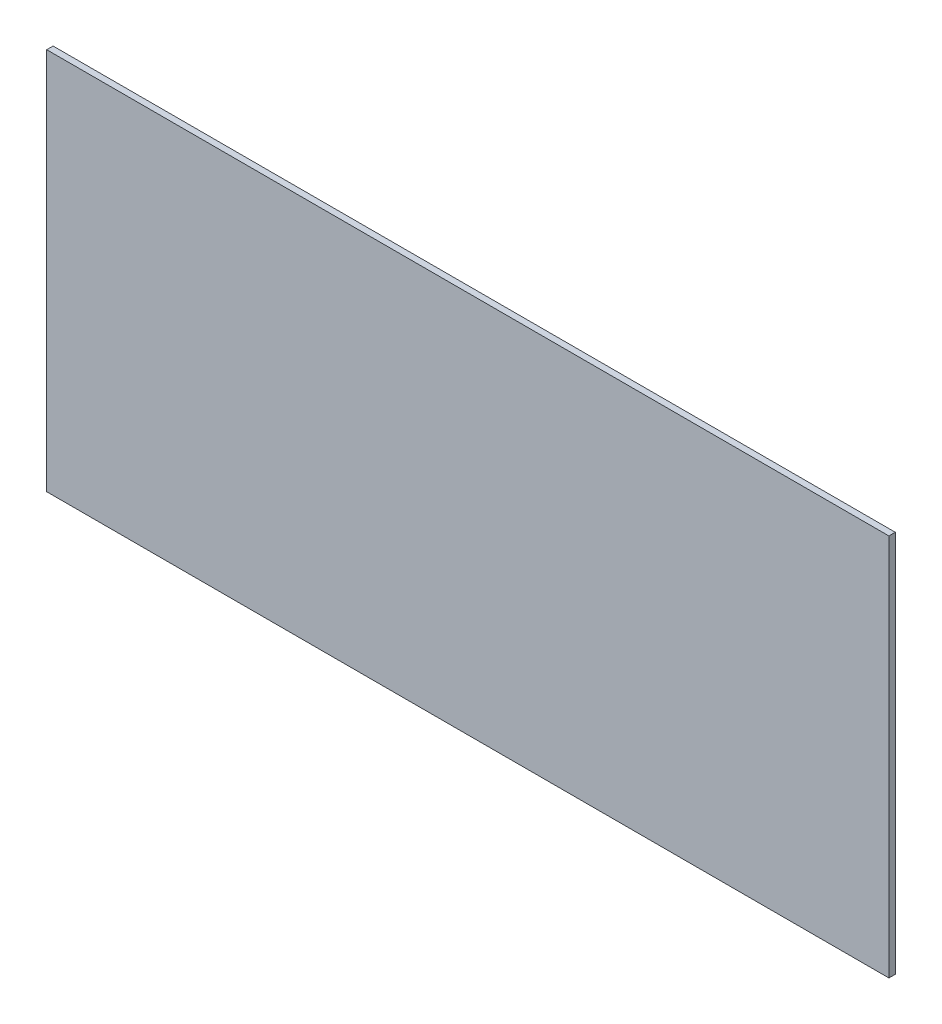
from build123d import *

# Parameters (mm, degrees)
SKETCH1_W           = 132
SKETCH1_H           = 60
BOSS_EXTRUDE1_DEPTH = 1


with BuildPart() as part:
    # Sketch1 → Boss-Extrude1 (new body)
    with BuildSketch(Plane.XY):
        with Locations((-8.123462833, 16.021174275)):
            Rectangle(SKETCH1_W, SKETCH1_H)
    extrude(amount=BOSS_EXTRUDE1_DEPTH)


solid = part.part
